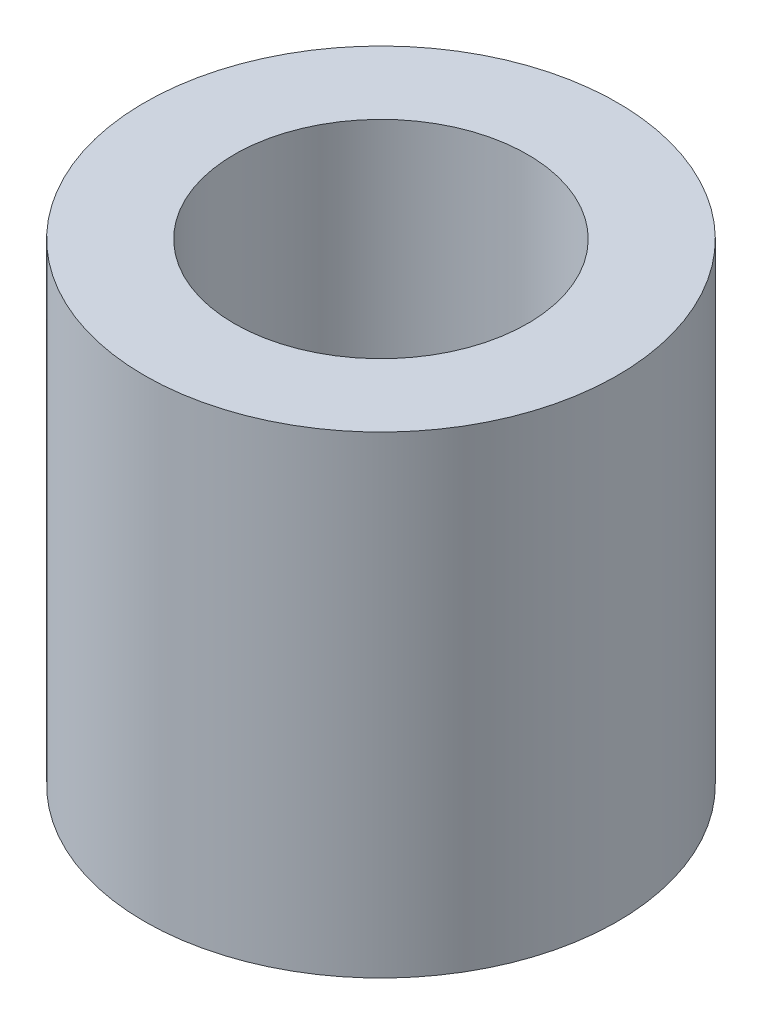
from build123d import *

# Parameters (mm, degrees)
SKETCH_1_R      = 2.5
SKETCH_1_R_2    = 1.55
EXTRUDE_1_DEPTH = 5


with BuildPart() as part:
    # 草图1 → 凸台-拉伸1 (new body)
    with BuildSketch(Plane(origin=(0, 0, 0), x_dir=(1, 0, 0), z_dir=(0, 1, 0))):
        Circle(SKETCH_1_R)
        Circle(SKETCH_1_R_2, mode=Mode.SUBTRACT)
    extrude(amount=EXTRUDE_1_DEPTH)


solid = part.part
